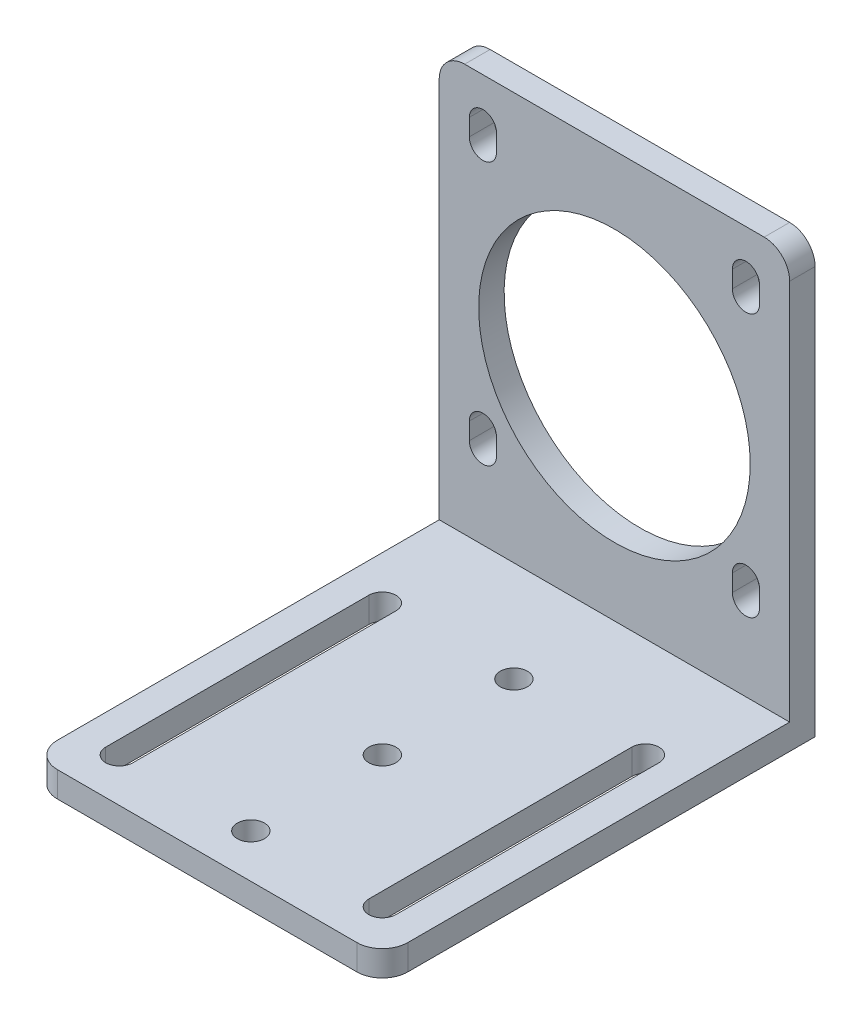
from build123d import *

# Parameters (mm, degrees)
BOSS_EXTRUDE1_DEPTH = 41.3
SKETCH2_R           = 16
CUT_EXTRUDE2_DEPTH  = 41.3
CUT_EXTRUDE7_DEPTH  = 41.3
SKETCH8_R           = 1.6
CUT_EXTRUDE8_DEPTH  = 41.3
FILLET1_R           = 3


with BuildPart() as part:
    # Sketch1 → Boss-Extrude1 (new body)
    with BuildSketch(Plane(origin=(0, 0, 0), x_dir=(0, 0, -1), z_dir=(1, 0, 0))):
        Polygon((-1.5, -22.5), (-49.5, -22.5), (-49.5, -25.5), (1.5, -25.5), (1.5, -22.5), (1.5, 25.5), (-1.5, 25.5), align=None)
    extrude(amount=BOSS_EXTRUDE1_DEPTH)

    # Sketch2 → Cut-Extrude2 (cut)
    with BuildSketch(Plane.XY.offset(1.5)):
        with Locations((20.65, 1.5)):
            Circle(SKETCH2_R)
    extrude(amount=-CUT_EXTRUDE2_DEPTH, mode=Mode.SUBTRACT)

    # Sketch4 → Cut-Extrude7 (cut)
    with BuildSketch(Plane(origin=(0, 0, -1.5), x_dir=(-1, 0, 0), z_dir=(0, 0, -1))):
        with BuildLine():
            Line((-3.557549808, 20.356030754), (-3.550011366, 18.356044961))
            ThreePointArc((-3.550011366, 18.356044961), (-5.143969246, 16.750025573), (-6.749988634, 18.343983453))
            Line((-6.749988634, 18.343983453), (-6.757527076, 20.343969246))
            ThreePointArc((-6.757527076, 20.343969246), (-5.163569196, 21.949988634), (-3.557549808, 20.356030754))
        make_face()
        with BuildLine():
            Line((-34.55, 20.35), (-34.55, 18.35))
            ThreePointArc((-34.55, 18.35), (-36.15, 16.75), (-37.75, 18.35))
            Line((-37.75, 18.35), (-37.75, 20.35))
            ThreePointArc((-37.75, 20.35), (-36.15, 21.95), (-34.55, 20.35))
        make_face()
        with BuildLine():
            Line((-3.55, -10.65), (-3.55, -12.65))
            ThreePointArc((-3.55, -12.65), (-5.15, -14.25), (-6.75, -12.65))
            Line((-6.75, -12.65), (-6.75, -10.65))
            ThreePointArc((-6.75, -10.65), (-5.15, -9.05), (-3.55, -10.65))
        make_face()
        with BuildLine():
            Line((-34.55, -10.65), (-34.55, -12.65))
            ThreePointArc((-34.55, -12.65), (-36.15, -14.25), (-37.75, -12.65))
            Line((-37.75, -12.65), (-37.75, -10.65))
            ThreePointArc((-37.75, -10.65), (-36.15, -9.05), (-34.55, -10.65))
        make_face()
    extrude(amount=-CUT_EXTRUDE7_DEPTH, mode=Mode.SUBTRACT)

    # Sketch8 → Cut-Extrude8 (cut)
    with BuildSketch(Plane.XZ.offset(25.5)):
        with Locations((20.65, 44.35)):
            Circle(SKETCH8_R)
        with Locations((20.65, 13.35)):
            Circle(SKETCH8_R)
        with Locations((20.65, 28.85)):
            Circle(SKETCH8_R)
        with BuildLine():
            Line((37.75, 44.35), (37.75, 13.35))
            ThreePointArc((37.75, 13.35), (36.15, 11.75), (34.55, 13.35))
            Line((34.55, 13.35), (34.55, 44.35))
            ThreePointArc((34.55, 44.35), (36.15, 45.95), (37.75, 44.35))
        make_face()
        with BuildLine():
            Line((6.75, 44.35), (6.75, 13.35))
            ThreePointArc((6.75, 13.35), (5.15, 11.75), (3.55, 13.35))
            Line((3.55, 13.35), (3.55, 44.35))
            ThreePointArc((3.55, 44.35), (5.15, 45.95), (6.75, 44.35))
        make_face()
    extrude(amount=-CUT_EXTRUDE8_DEPTH, mode=Mode.SUBTRACT)

    # Fillet1
    fillet1_edges = [part.edges().sort_by_distance(p)[0] for p in [
        (41.3, 25.5, 0),
        (41.3, -24, 49.5),
        (0, -24, 49.5),
        (0, 25.5, 0),
    ]]
    fillet(fillet1_edges, radius=FILLET1_R)


solid = part.part
